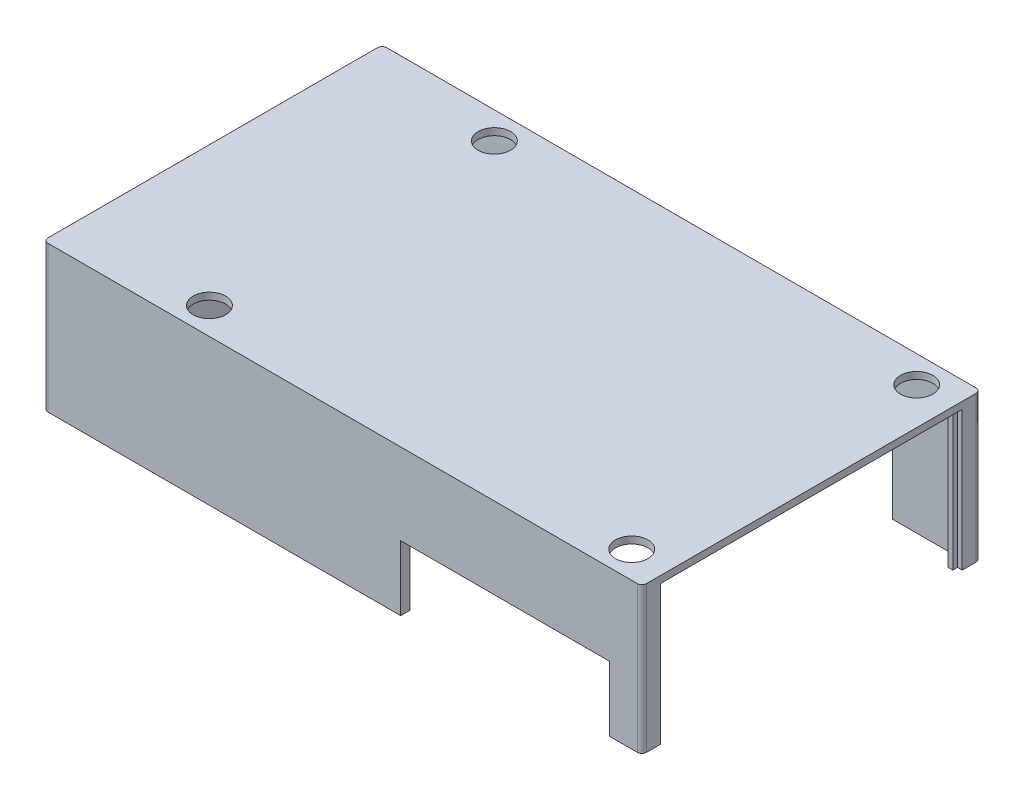
from build123d import *

# Parameters (mm, degrees)
SKETCH_2_W          = 129
SKETCH_2_H          = 73
EXTRUDE_1_DEPTH     = 1.5
SKETCH_2_4_W        = 2
SKETCH_2_4_H        = 69
EXTRUDE_2_DEPTH     = 30
SKETCH_2_5_W        = 129
SKETCH_2_5_H        = 2
EXTRUDE_3_DEPTH     = 30
SKETCH_2_6_W        = 129
SKETCH_2_6_H        = 2
EXTRUDE_4_DEPTH     = 30
SKETCH_5_W          = 45
SKETCH_5_H          = 2
CUT_EXTRUDE_2_DEPTH = 14
SKETCH_6_W          = 20
SKETCH_6_H          = 2
CUT_EXTRUDE_3_DEPTH = 14
FILLET_1_R          = 1
FILLET_2_R          = 1
FILLET_5_R          = 1
SKETCH_8_R          = 3.5
CUT_EXTRUDE_4_DEPTH = 10
FILLET_6_R          = 1
EXTRUDE_5_DEPTH     = 30


with BuildPart() as part:
    # 草图2 → 凸台-拉伸1 (new body)
    with BuildSketch(Plane(origin=(0, 0, 0), x_dir=(1, 0, 0), z_dir=(0, 1, 0))):
        Rectangle(SKETCH_2_W, SKETCH_2_H)
    extrude(amount=EXTRUDE_1_DEPTH)

    # 草图2<4> → 凸台-拉伸2 (add)
    with BuildSketch(Plane(origin=(0, 0, 0), x_dir=(1, 0, 0), z_dir=(0, 1, 0))):
        with Locations((-63.5, 0)):
            Rectangle(SKETCH_2_4_W, SKETCH_2_4_H)
    extrude(amount=-EXTRUDE_2_DEPTH)

    # 草图2<5> → 凸台-拉伸3 (add)
    with BuildSketch(Plane(origin=(0, 0, 0), x_dir=(1, 0, 0), z_dir=(0, 1, 0))):
        with Locations((0, 35.5)):
            Rectangle(SKETCH_2_5_W, SKETCH_2_5_H)
    extrude(amount=-EXTRUDE_3_DEPTH)

    # 草图2<6> → 凸台-拉伸4 (add)
    with BuildSketch(Plane(origin=(0, 0, 0), x_dir=(1, 0, 0), z_dir=(0, 1, 0))):
        with Locations((0, -35.5)):
            Rectangle(SKETCH_2_6_W, SKETCH_2_6_H)
    extrude(amount=-EXTRUDE_4_DEPTH)

    # 草图5 → 切除-拉伸2 (cut)
    with BuildSketch(Plane.XZ.offset(30)):
        with Locations((35, 35.5)):
            Rectangle(SKETCH_5_W, SKETCH_5_H)
    extrude(amount=-CUT_EXTRUDE_2_DEPTH, mode=Mode.SUBTRACT)

    # 草图6 → 切除-拉伸3 (cut)
    with BuildSketch(Plane.XZ.offset(30)):
        with Locations((37.5, -35.5)):
            Rectangle(SKETCH_6_W, SKETCH_6_H)
    extrude(amount=-CUT_EXTRUDE_3_DEPTH, mode=Mode.SUBTRACT)

    # 圆角1
    fillet_1_edges = [part.edges().sort_by_distance(p)[0] for p in [
        (-64.5, -14.25, -36.5),
    ]]
    fillet(fillet_1_edges, radius=FILLET_1_R)

    # 圆角2
    fillet_2_edges = [part.edges().sort_by_distance(p)[0] for p in [
        (-64.5, -14.25, 36.5),
    ]]
    fillet(fillet_2_edges, radius=FILLET_2_R)

    # 圆角5
    fillet_5_edges = [part.edges().sort_by_distance(p)[0] for p in [
        (64.5, -14.25, 36.5),
    ]]
    fillet(fillet_5_edges, radius=FILLET_5_R)

    # 草图8 → 切除-拉伸4 (cut)
    with BuildSketch(Plane(origin=(0, 1.5, 0), x_dir=(1, 0, 0), z_dir=(0, 1, 0))):
        with Locations((-34.5, 30.7)):
            Circle(SKETCH_8_R)
        with Locations((56.5, 30.7)):
            Circle(SKETCH_8_R)
        with Locations((-34.5, -30.7)):
            Circle(SKETCH_8_R)
        with Locations((56.5, -30.7)):
            Circle(SKETCH_8_R)
    extrude(amount=-CUT_EXTRUDE_4_DEPTH, mode=Mode.SUBTRACT)

    # 圆角6
    fillet_6_edges = [part.edges().sort_by_distance(p)[0] for p in [
        (64.5, -14.25, -36.5),
    ]]
    fillet(fillet_6_edges, radius=FILLET_6_R)

    # 草图9 → 凸台-拉伸5 (add)
    with BuildSketch(Plane.XZ):
        Polygon((62.5, 34.5), (64.5, 34.5), (64.5, 32.5), (63.5, 32.5), (63.5, 31.5), (62.5, 31.5), align=None)
        Polygon((62.5, -34.5), (62.5, -31.5), (63.5, -31.5), (63.5, -32.5), (64.5, -32.5), (64.5, -34.5), align=None)
    extrude(amount=EXTRUDE_5_DEPTH)


solid = part.part
